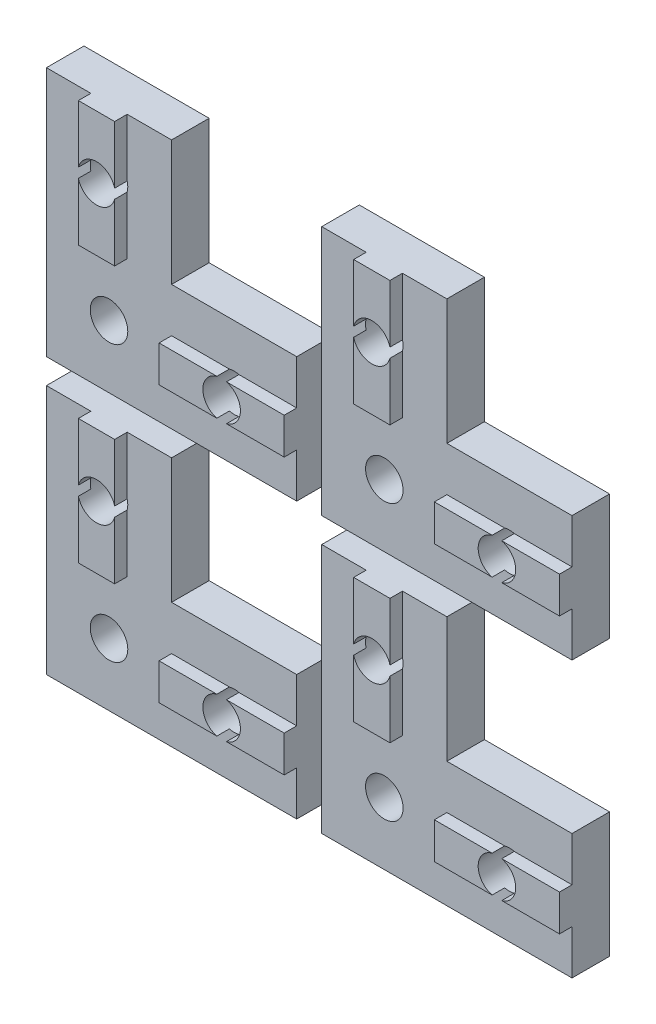
from build123d import *

# Parameters (mm, degrees)
BOSS_EXTRU_1_DEPTH      = 3
ESQUISSE2_W             = 2.9
ESQUISSE2_H             = 10
ESQUISSE2_W_2           = 10
ESQUISSE2_H_2           = 2.9
BOSS_EXTRU_2_DEPTH      = 1
ESQUISSE4_R             = 1.5
ENL_V_MAT_EXTRU_2_DEPTH = 5
LPATTERN1_COUNT         = 2
LPATTERN1_PITCH         = 22
LPATTERN1_2_COUNT       = 2
LPATTERN1_2_PITCH       = 22


with BuildPart() as part:
    # Esquisse1 → Boss.-Extru.1 (new body)
    with BuildSketch(Plane.XY):
        Polygon((0, 0), (20, 0), (20, 10), (10, 10), (10, 20), (0, 20), align=None)
    extrude(amount=BOSS_EXTRU_1_DEPTH)

    # Esquisse2 → Boss.-Extru.2 (add)
    with BuildSketch(Plane.XY.offset(3)):
        with Locations((5, 15)):
            Rectangle(ESQUISSE2_W, ESQUISSE2_H)
        with Locations((15, 5)):
            Rectangle(ESQUISSE2_W_2, ESQUISSE2_H_2)
    extrude(amount=BOSS_EXTRU_2_DEPTH)

    # Esquisse4 → Enlèv. mat.-Extru.2 (cut, through all)
    with BuildSketch(Plane.XY.offset(4)):
        with Locations((5, 15)):
            Circle(ESQUISSE4_R)
        with Locations((5, 5)):
            Circle(ESQUISSE4_R)
        with Locations((15, 5)):
            Circle(ESQUISSE4_R)
    extrude(amount=-ENL_V_MAT_EXTRU_2_DEPTH, mode=Mode.SUBTRACT)


with BuildPart() as lpattern1_1:
    # LPattern1: pattern copy
    add(part.part.moved(Location(Vector(1, 0, 0) * (1 * LPATTERN1_PITCH))))


with BuildPart() as lpattern1_2_1:
    # LPattern1 2: pattern copy
    add(part.part.moved(Location(Vector(0, -1, 0) * (1 * LPATTERN1_2_PITCH))))


with BuildPart() as lpattern1_2_2:
    # LPattern1 2: pattern copy
    add(lpattern1_1.part.moved(Location(Vector(0, -1, 0) * (1 * LPATTERN1_2_PITCH))))


solid = Compound([part.part, lpattern1_1.part, lpattern1_2_1.part, lpattern1_2_2.part])
